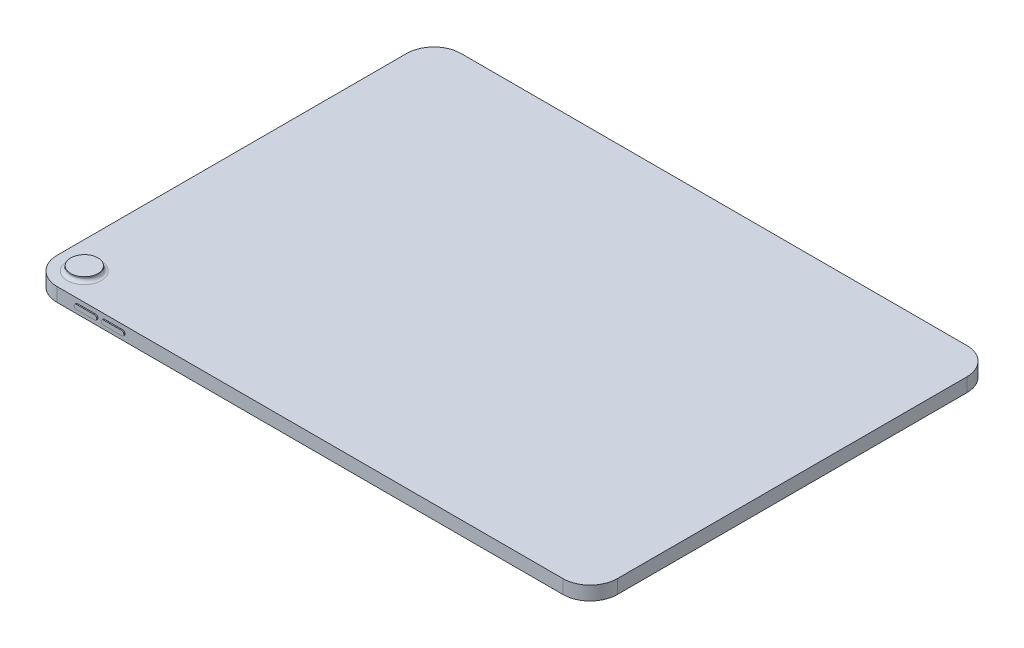
from build123d import *

# Parameters (mm, degrees)
SKIZZE1_W                       = 247.6
SKIZZE1_H                       = 178.5
AUFSATZ_LINEAR_AUSTRAGEN1_DEPTH = 6.1
VERRUNDUNG1_R                   = 12
SKIZZE2_R                       = 6
AUFSATZ_LINEAR_AUSTRAGEN2_DEPTH = 2
VERRUNDUNG2_R                   = 1.5
AUFSATZ_LINEAR_AUSTRAGEN3_DEPTH = 0.5
AUFSATZ_LINEAR_AUSTRAGEN5_DEPTH = 0.5


with BuildPart() as part:
    # Skizze1 → Aufsatz-Linear austragen1 (new body)
    with BuildSketch(Plane(origin=(0, 0, 0), x_dir=(1, 0, 0), z_dir=(0, 1, 0))):
        Rectangle(SKIZZE1_W, SKIZZE1_H)
    extrude(amount=AUFSATZ_LINEAR_AUSTRAGEN1_DEPTH)

    # Verrundung1
    verrundung1_edges = [part.edges().sort_by_distance(p)[0] for p in [
        (-123.8, 3.05, -89.25),
        (123.8, 3.05, -89.25),
        (123.8, 3.05, 89.25),
        (-123.8, 3.05, 89.25),
    ]]
    fillet(verrundung1_edges, radius=VERRUNDUNG1_R)

    # Skizze2 → Aufsatz-Linear austragen2 (add)
    with BuildSketch(Plane(origin=(0, 6.1, 0), x_dir=(1, 0, 0), z_dir=(0, 1, 0))):
        with Locations((-111.8, -77.25)):
            Circle(SKIZZE2_R)
    extrude(amount=AUFSATZ_LINEAR_AUSTRAGEN2_DEPTH)

    # Verrundung2
    verrundung2_edges = [part.edges().sort_by_distance(p)[0] for p in [
        (-117.8, 6.1, 77.25),
    ]]
    fillet(verrundung2_edges, radius=VERRUNDUNG2_R)

    # Skizze3 → Aufsatz-Linear austragen3 (add)
    with BuildSketch(Plane.ZY.offset(123.8)):
        with BuildLine():
            Line((74.4, 1.2), (61.1, 1.2))
            ThreePointArc((61.1, 1.2), (59.25, 3.05), (61.1, 4.9))
            Line((61.1, 4.9), (74.4, 4.9))
            ThreePointArc((74.4, 4.9), (76.25, 3.05), (74.4, 1.2))
        make_face()
    extrude(amount=AUFSATZ_LINEAR_AUSTRAGEN3_DEPTH)

    # Skizze4 → Aufsatz-Linear austragen5 (add)
    with BuildSketch(Plane.XY.offset(89.25)):
        with BuildLine():
            Line((-102.8, 4.05), (-94.8, 4.05))
            ThreePointArc((-94.8, 4.05), (-93.8, 3.05), (-94.8, 2.05))
            Line((-94.8, 2.05), (-102.8, 2.05))
            ThreePointArc((-102.8, 2.05), (-103.8, 3.05), (-102.8, 4.05))
        make_face()
        with BuildLine():
            Line((-90.8, 4.05), (-82.8, 4.05))
            ThreePointArc((-82.8, 4.05), (-81.8, 3.05), (-82.8, 2.05))
            Line((-82.8, 2.05), (-90.8, 2.05))
            ThreePointArc((-90.8, 2.05), (-91.8, 3.05), (-90.8, 4.05))
        make_face()
    extrude(amount=AUFSATZ_LINEAR_AUSTRAGEN5_DEPTH)


solid = part.part
